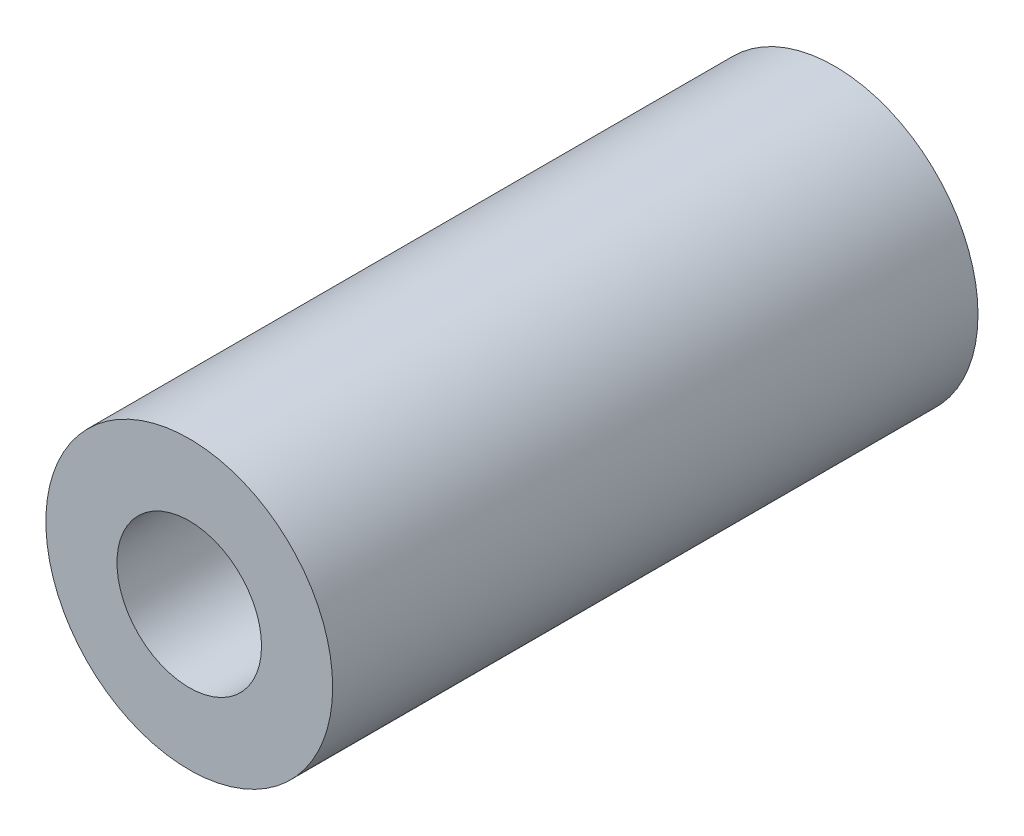
from build123d import *

# Parameters (mm, degrees)
SKETCH1_R      = 6.35
SKETCH1_R_2    = 3.2004
EXTRUDE1_DEPTH = 14.2875


with BuildPart() as part:
    # Sketch1 → Extrude1 (new body, symmetric)
    with BuildSketch(Plane.XY):
        Circle(SKETCH1_R)
        Circle(SKETCH1_R_2, mode=Mode.SUBTRACT)
    extrude(amount=EXTRUDE1_DEPTH, both=True)


solid = part.part
